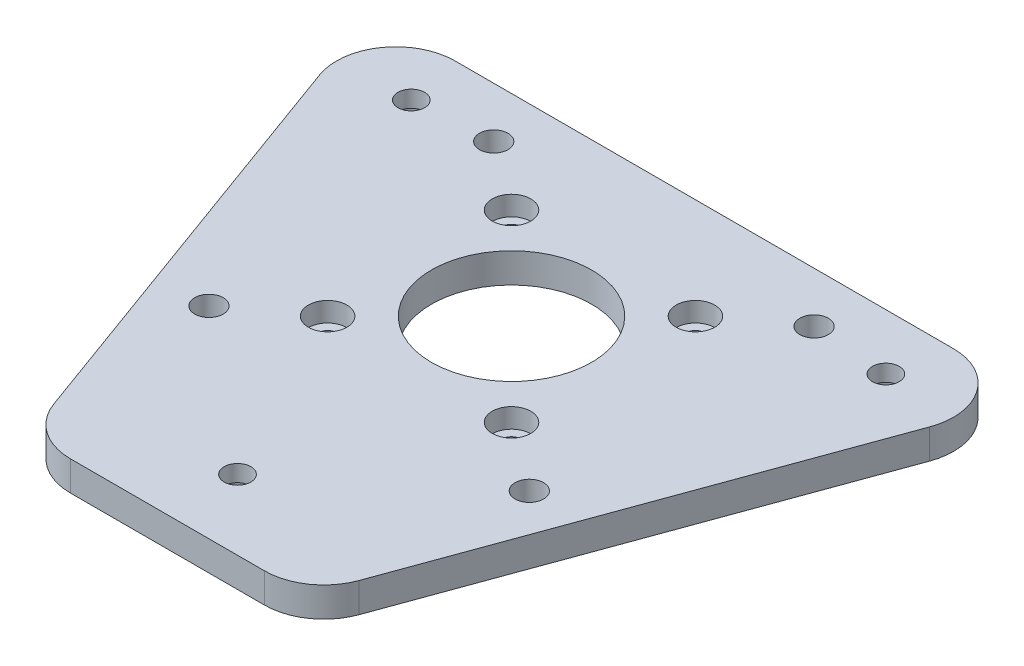
from build123d import *

# Parameters (mm, degrees)
SKETCH2_W                                        = 130
SKETCH2_H                                        = 130
BOSS_EXTRUDE1_DEPTH                              = 5
SKETCH3_R                                        = 13.5
CUT_EXTRUDE1_DEPTH                               = 5
SKETCH8_W                                        = 130
SKETCH8_H                                        = 130
CUT_EXTRUDE6_DEPTH                               = 6
M4_CLEARANCE_HOLE1_D                             = 4.8
M4_CLEARANCE_HOLE1_DEPTH                         = 5
CBORE_FOR_M3_HEX_HEAD_MACHINE_SCREW1_D           = 3.4
CBORE_FOR_M3_HEX_HEAD_MACHINE_SCREW1_DEPTH       = 5
CBORE_FOR_M3_HEX_HEAD_MACHINE_SCREW1_CBORE_D     = 6.5
CBORE_FOR_M3_HEX_HEAD_MACHINE_SCREW1_CBORE_DEPTH = 3.3
CBORE_FOR_M4_SBHCS1_D                            = 4.5
CBORE_FOR_M4_SBHCS1_DEPTH                        = 5
CBORE_FOR_M4_SBHCS1_CBORE_D                      = 8.6
CBORE_FOR_M4_SBHCS1_CBORE_DEPTH                  = 2.2


with BuildPart() as part:
    # Sketch2 → Boss-Extrude1 (new body)
    with BuildSketch(Plane(origin=(0, 0, 0), x_dir=(1, 0, 0), z_dir=(0, 1, 0))):
        Rectangle(SKETCH2_W, SKETCH2_H)
    extrude(amount=BOSS_EXTRUDE1_DEPTH)

    # Sketch3 → Cut-Extrude1 (cut)
    with BuildSketch(Plane(origin=(0, 5, 0), x_dir=(1, 0, 0), z_dir=(0, 1, 0))):
        Circle(SKETCH3_R)
    extrude(amount=-CUT_EXTRUDE1_DEPTH, mode=Mode.SUBTRACT)

    # Sketch8 → Cut-Extrude6 (cut, through all)
    with BuildSketch(Plane(origin=(0, 5, 0), x_dir=(1, 0, 0), z_dir=(0, 1, 0))):
        Rectangle(SKETCH8_W, SKETCH8_H)
        with BuildLine():
            Line((-42.00982343, 32.5), (42.00982343, 32.5))
            ThreePointArc((42.00982343, 32.5), (50.201409492, 28.235670649), (51.406671379, 19.079583559))
            Line((51.406671379, 19.079583559), (25.74494306, -51.420416441))
            ThreePointArc((25.74494306, -51.420416441), (22.083765761, -56.191586062), (16.348095112, -58))
            Line((16.348095112, -58), (-16.348095112, -58))
            ThreePointArc((-16.348095112, -58), (-22.083765761, -56.191586062), (-25.74494306, -51.420416441))
            Line((-25.74494306, -51.420416441), (-51.406671379, 19.079583559))
            ThreePointArc((-51.406671379, 19.079583559), (-50.201409492, 28.235670649), (-42.00982343, 32.5))
        make_face(mode=Mode.SUBTRACT)
    extrude(amount=-CUT_EXTRUDE6_DEPTH, mode=Mode.SUBTRACT)

    # M4 Clearance Hole1
    with Locations(Plane(origin=(0, 5, 0), x_dir=(1, 0, 0), z_dir=(0, 1, 0))):
        with Locations((-27, 24), (27, 24), (27, -24), (-27, -24)):
            Hole(M4_CLEARANCE_HOLE1_D / 2, depth=M4_CLEARANCE_HOLE1_DEPTH)

    # CBORE for M3 Hex Head Machine Screw1
    with Locations(Plane(origin=(0, 5, 0), x_dir=(1, 0, 0), z_dir=(0, 1, 0))):
        with Locations((-15.5, 15.5), (15.5, 15.5), (15.5, -15.5), (-15.5, -15.5)):
            CounterBoreHole(CBORE_FOR_M3_HEX_HEAD_MACHINE_SCREW1_D / 2, CBORE_FOR_M3_HEX_HEAD_MACHINE_SCREW1_CBORE_D / 2, CBORE_FOR_M3_HEX_HEAD_MACHINE_SCREW1_CBORE_DEPTH, depth=CBORE_FOR_M3_HEX_HEAD_MACHINE_SCREW1_DEPTH)

    # CBORE for M4 SBHCS1
    with Locations(Plane(origin=(0, 0, 0), x_dir=(-1, 0, 0), z_dir=(0, -1, 0))):
        with Locations((0, -46.19), (40, 23.1), (-40, 23.1)):
            CounterBoreHole(CBORE_FOR_M4_SBHCS1_D / 2, CBORE_FOR_M4_SBHCS1_CBORE_D / 2, CBORE_FOR_M4_SBHCS1_CBORE_DEPTH, depth=CBORE_FOR_M4_SBHCS1_DEPTH)


solid = part.part
